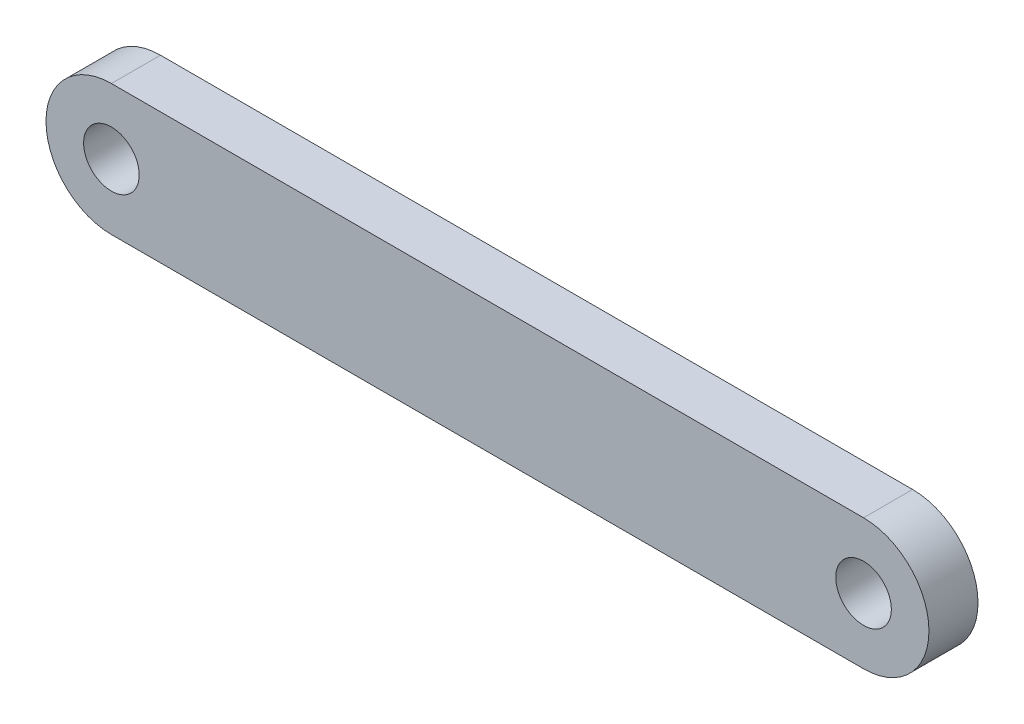
from build123d import *

# Parameters (mm, degrees)
ESQUISSE1_R        = 1.7
BOSS_EXTRU_1_DEPTH = 3


with BuildPart() as part:
    # Esquisse1 → Boss.-Extru.1 (new body)
    with BuildSketch(Plane.XY):
        with BuildLine():
            Line((50, 8), (4, 8))
            ThreePointArc((4, 8), (0, 4), (4, 0))
            Line((4, 0), (50, 0))
            ThreePointArc((50, 0), (54, 4), (50, 8))
        make_face()
        with Locations((4, 4)):
            Circle(ESQUISSE1_R, mode=Mode.SUBTRACT)
        with Locations((50, 4)):
            Circle(ESQUISSE1_R, mode=Mode.SUBTRACT)
    extrude(amount=BOSS_EXTRU_1_DEPTH)


solid = part.part
